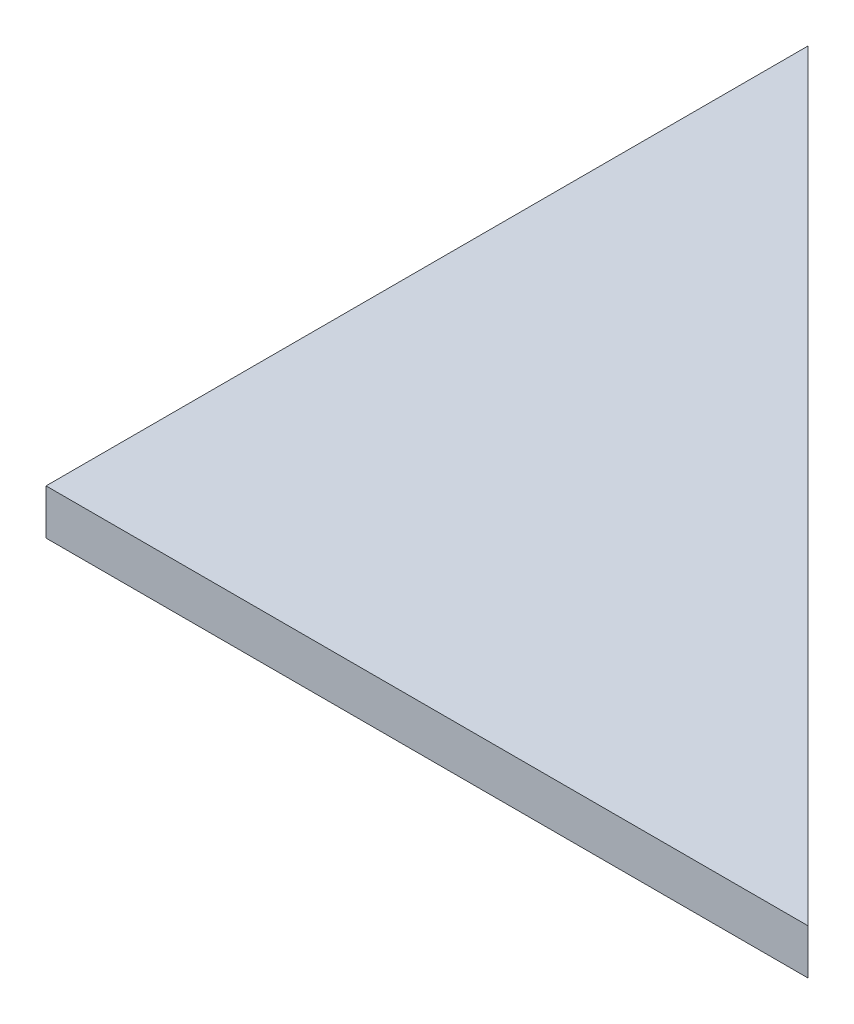
from build123d import *

# Parameters (mm, degrees)
BOSS_EXTRUDE1_DEPTH = 3


with BuildPart() as part:
    # Sketch1 → Boss-Extrude1 (new body)
    with BuildSketch(Plane(origin=(0, 0, 0), x_dir=(1, 0, 0), z_dir=(0, 1, 0))):
        Polygon((0, 0), (50.5, 0), (0, 50.5), align=None)
    extrude(amount=BOSS_EXTRUDE1_DEPTH)


solid = part.part
